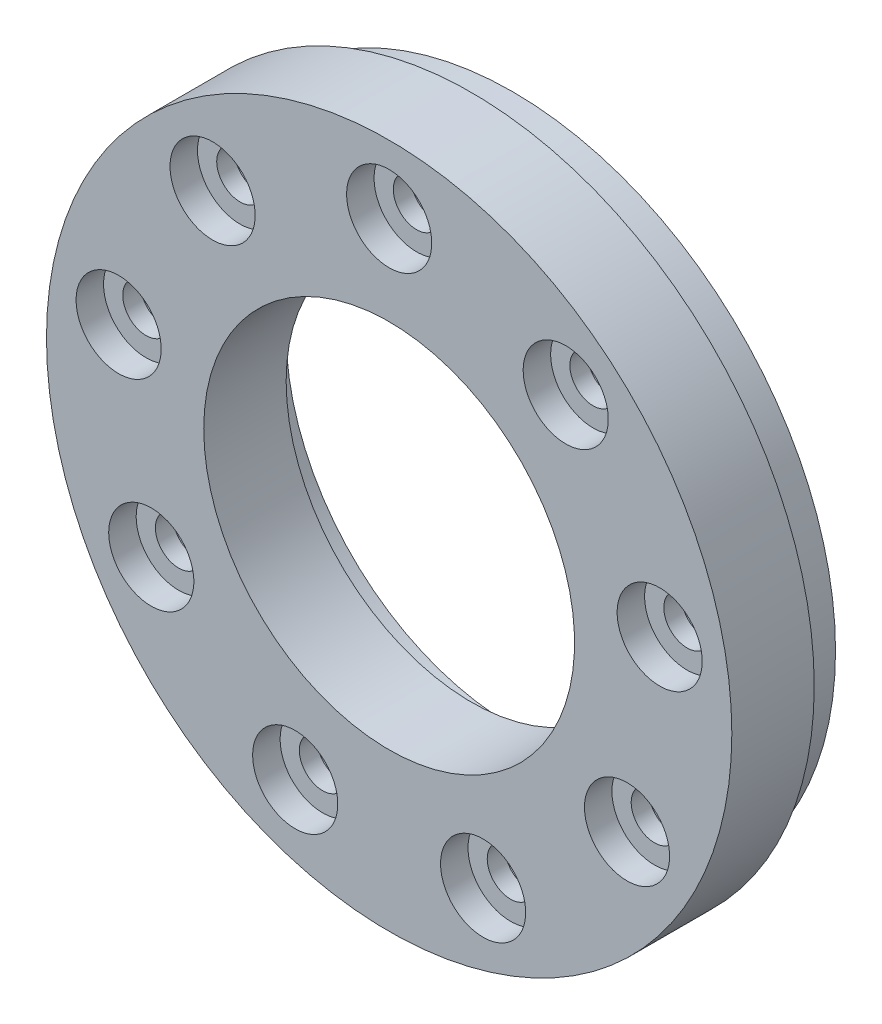
from build123d import *

# Parameters (mm, degrees)
ESQUISSE1_R             = 24.95
BOSS_EXTRU_1_DEPTH      = 6
ESQUISSE3_R             = 3.1
ENL_V_MAT_EXTRU_1_DEPTH = 2
ESQUISSE4_R             = 1.7
ENL_V_MAT_EXTRU_2_DEPTH = 7
ESQUISSE5_R             = 23.5
ESQUISSE5_R_2           = 16.5
ESQUISSE5_R_3           = 1.7
BOSS_EXTRU_2_DEPTH      = 3
ESQUISSE6_R             = 2.1
ENL_V_MAT_EXTRU_3_DEPTH = 5.7
ESQUISSE7_R             = 13.5
ENL_V_MAT_EXTRU_4_DEPTH = 7


with BuildPart() as part:
    # Esquisse1 → Boss.-Extru.1 (new body)
    with BuildSketch(Plane.XY):
        Circle(ESQUISSE1_R)
    extrude(amount=BOSS_EXTRU_1_DEPTH)

    # Esquisse3 → Enlèv. mat.-Extru.1 (cut)
    with BuildSketch(Plane(origin=(0, 0, 6), x_dir=(-1, 0, 0), z_dir=(0, 0, -1))):
        with Locations((0, 20)):
            Circle(ESQUISSE3_R)
        with Locations((12.855752194, 15.320888862)):
            Circle(ESQUISSE3_R)
        with Locations((19.69615506, 3.472963553)):
            Circle(ESQUISSE3_R)
        with Locations((17.320508076, -10)):
            Circle(ESQUISSE3_R)
        with Locations((6.840402867, -18.793852416)):
            Circle(ESQUISSE3_R)
        with Locations((-6.840402867, -18.793852416)):
            Circle(ESQUISSE3_R)
        with Locations((-17.320508076, -10)):
            Circle(ESQUISSE3_R)
        with Locations((-19.69615506, 3.472963553)):
            Circle(ESQUISSE3_R)
        with Locations((-12.855752194, 15.320888862)):
            Circle(ESQUISSE3_R)
    extrude(amount=ENL_V_MAT_EXTRU_1_DEPTH, mode=Mode.SUBTRACT)

    # Esquisse4 → Enlèv. mat.-Extru.2 (cut, through all)
    with BuildSketch(Plane(origin=(0, 0, 0), x_dir=(-1, 0, 0), z_dir=(0, 0, -1))):
        with Locations((0, 20)):
            Circle(ESQUISSE4_R)
        with Locations((12.855752194, 15.320888862)):
            Circle(ESQUISSE4_R)
        with Locations((19.69615506, 3.472963553)):
            Circle(ESQUISSE4_R)
        with Locations((17.320508076, -10)):
            Circle(ESQUISSE4_R)
        with Locations((6.840402867, -18.793852416)):
            Circle(ESQUISSE4_R)
        with Locations((-6.840402867, -18.793852416)):
            Circle(ESQUISSE4_R)
        with Locations((-17.320508076, -10)):
            Circle(ESQUISSE4_R)
        with Locations((-19.69615506, 3.472963553)):
            Circle(ESQUISSE4_R)
        with Locations((-12.855752194, 15.320888862)):
            Circle(ESQUISSE4_R)
    extrude(amount=-ENL_V_MAT_EXTRU_2_DEPTH, mode=Mode.SUBTRACT)

    # Esquisse5 → Boss.-Extru.2 (add)
    with BuildSketch(Plane(origin=(0, 0, 0), x_dir=(-1, 0, 0), z_dir=(0, 0, -1))):
        Circle(ESQUISSE5_R)
        Circle(ESQUISSE5_R_2, mode=Mode.SUBTRACT)
        with Locations((-12.855752194, 15.320888862)):
            Circle(ESQUISSE5_R_3, mode=Mode.SUBTRACT)
        with Locations((-19.69615506, 3.472963553)):
            Circle(ESQUISSE5_R_3, mode=Mode.SUBTRACT)
        with Locations((-17.320508076, -10)):
            Circle(ESQUISSE5_R_3, mode=Mode.SUBTRACT)
        with Locations((-6.840402867, -18.793852416)):
            Circle(ESQUISSE5_R_3, mode=Mode.SUBTRACT)
        with Locations((6.840402867, -18.793852416)):
            Circle(ESQUISSE5_R_3, mode=Mode.SUBTRACT)
        with Locations((17.320508076, -10)):
            Circle(ESQUISSE5_R_3, mode=Mode.SUBTRACT)
        with Locations((19.69615506, 3.472963553)):
            Circle(ESQUISSE5_R_3, mode=Mode.SUBTRACT)
        with Locations((12.855752194, 15.320888862)):
            Circle(ESQUISSE5_R_3, mode=Mode.SUBTRACT)
        with Locations((0, 20)):
            Circle(ESQUISSE5_R_3, mode=Mode.SUBTRACT)
    extrude(amount=BOSS_EXTRU_2_DEPTH)

    # Esquisse6 → Enlèv. mat.-Extru.3 (cut)
    with BuildSketch(Plane(origin=(0, 0, -3), x_dir=(-1, 0, 0), z_dir=(0, 0, -1))):
        with Locations((12.855752194, 15.320888862)):
            Circle(ESQUISSE6_R)
        with Locations((19.69615506, 3.472963553)):
            Circle(ESQUISSE6_R)
        with Locations((17.320508076, -10)):
            Circle(ESQUISSE6_R)
        with Locations((6.840402867, -18.793852416)):
            Circle(ESQUISSE6_R)
        with Locations((-6.840402867, -18.793852416)):
            Circle(ESQUISSE6_R)
        with Locations((-17.320508076, -10)):
            Circle(ESQUISSE6_R)
        with Locations((-19.69615506, 3.472963553)):
            Circle(ESQUISSE6_R)
        with Locations((-12.855752194, 15.320888862)):
            Circle(ESQUISSE6_R)
        with Locations((0, 20)):
            Circle(ESQUISSE6_R)
    extrude(amount=-ENL_V_MAT_EXTRU_3_DEPTH, mode=Mode.SUBTRACT)

    # Esquisse7 → Enlèv. mat.-Extru.4 (cut, through all)
    with BuildSketch(Plane(origin=(0, 0, 0), x_dir=(-1, 0, 0), z_dir=(0, 0, -1))):
        Circle(ESQUISSE7_R)
    extrude(amount=-ENL_V_MAT_EXTRU_4_DEPTH, mode=Mode.SUBTRACT)


solid = part.part
